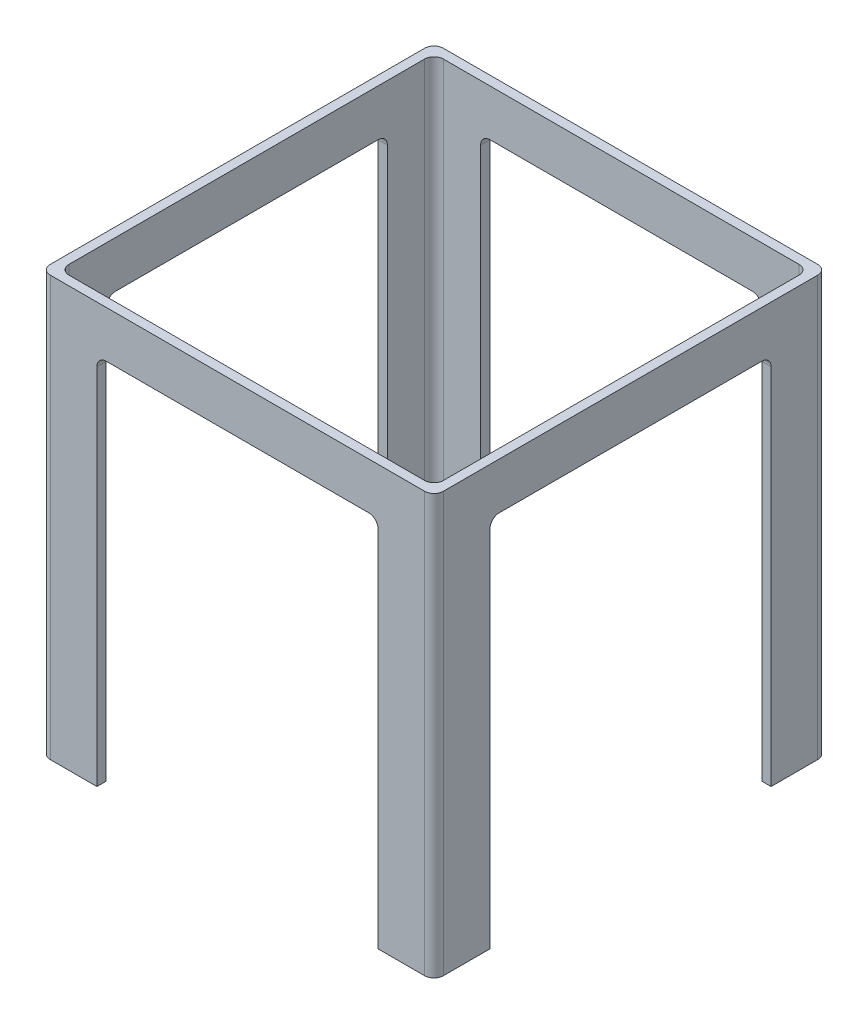
from build123d import *

# Parameters (mm, degrees)
SKETCH1_W            = 84.3
SKETCH1_H            = 84.3
SKETCH1_W_2          = 80.3
SKETCH1_H_2          = 80.3
BOSS_EXTRUDE1_DEPTH  = 10
BOSS_EXTRUDE2_DEPTH  = 80
MIRROR2_COPY_1_DEPTH = 80
FILLET1_R            = 2


with BuildPart() as part:
    # Sketch1 → Boss-Extrude1 (new body)
    with BuildSketch(Plane(origin=(0, 0, 0), x_dir=(1, 0, 0), z_dir=(0, 1, 0))):
        Rectangle(SKETCH1_W, SKETCH1_H)
        Rectangle(SKETCH1_W_2, SKETCH1_H_2, mode=Mode.SUBTRACT)
    extrude(amount=BOSS_EXTRUDE1_DEPTH)

    # Sketch2 → Boss-Extrude2 (add)
    with BuildSketch(Plane.XZ):
        Polygon((-42.15, 30.15), (-40.15, 30.15), (-40.15, 40.15), (-30.15, 40.15), (-30.15, 42.15), (-42.15, 42.15), align=None)
    boss_extrude2 = extrude(amount=BOSS_EXTRUDE2_DEPTH)

    # Mirror1: Boss-Extrude2 across plane
    add(boss_extrude2.mirror(Plane(origin=(0, 0, 0), x_dir=(0, 0, 1), z_dir=(1, 0, 0))))

    # Mirror2: Boss-Extrude2 across plane
    add(boss_extrude2.mirror(Plane.XY))

    # Mirror2 copy 1 sketch → Mirror2 copy 1 (add)
    with BuildSketch(Plane(origin=(0, 0, 0), x_dir=(-1, 0, 0), z_dir=(0, -1, 0))):
        Polygon((-42.15, 30.15), (-40.15, 30.15), (-40.15, 40.15), (-30.15, 40.15), (-30.15, 42.15), (-42.15, 42.15), align=None)
    extrude(amount=MIRROR2_COPY_1_DEPTH)

    # Fillet1
    fillet1_edges = [part.edges().sort_by_distance(p)[0] for p in [
        (40.15, -35, 40.15),
        (40.15, -35, -40.15),
        (-40.15, -35, -40.15),
        (-40.15, -35, 40.15),
        (-41.15, 0, 30.15),
        (-30.15, 0, 41.15),
        (30.15, 0, 41.15),
        (41.15, 0, 30.15),
        (-30.15, 0, -41.15),
        (-41.15, 0, -30.15),
        (-42.15, -35, -42.15),
        (42.15, -35, -42.15),
        (42.15, -35, 42.15),
        (-42.15, -35, 42.15),
        (41.15, 0, -30.15),
        (30.15, 0, -41.15),
    ]]
    fillet(fillet1_edges, radius=FILLET1_R)


solid = part.part
